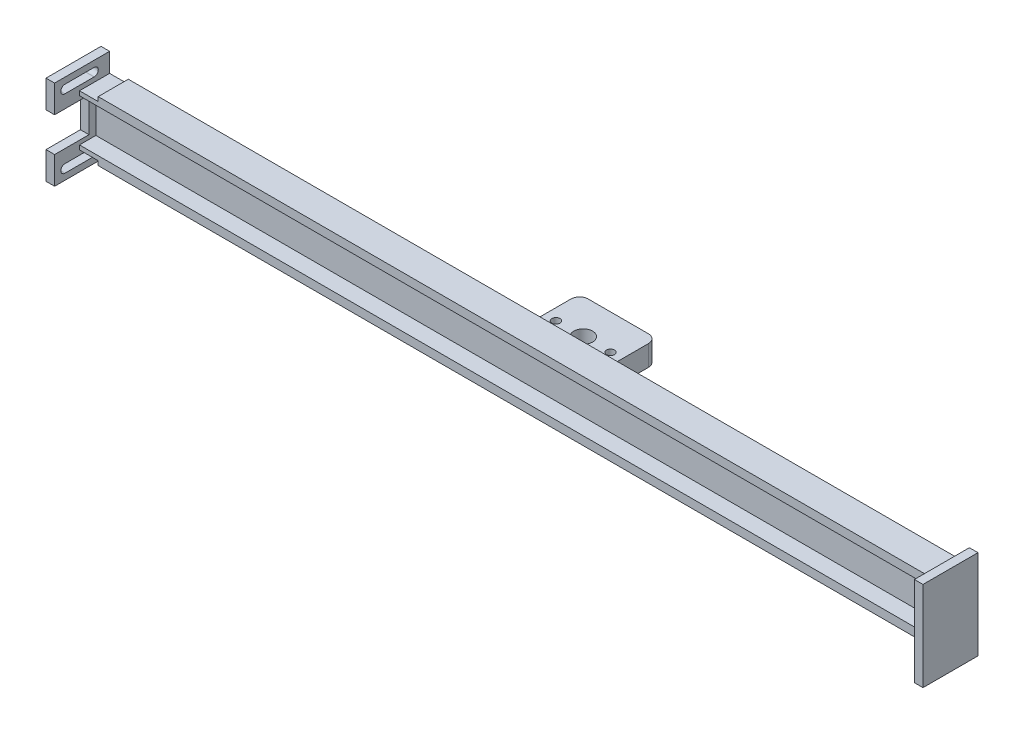
from build123d import *

# Parameters (mm, degrees)
BOSS_EXTRUDE1_DEPTH = 250
SKETCH16_W          = 22.5
SKETCH16_H          = 25.4
SKETCH16_R          = 1.175
SKETCH16_R_2        = 2.75
BOSS_EXTRUDE4_DEPTH = 6
SKETCH17_W          = 22.5
SKETCH17_H          = 6
CUT_EXTRUDE10_DEPTH = 2.5
SKETCH20_W          = 26
SKETCH20_H          = 16
BOSS_EXTRUDE7_DEPTH = 2.5
CUT_EXTRUDE12_DEPTH = 2.5
SKETCH22_W          = 10
SKETCH22_H          = 10
CUT_EXTRUDE13_DEPTH = 10
SKETCH23_W          = 5.437321705
SKETCH23_H          = 8.7625
CUT_EXTRUDE14_DEPTH = 1.25
SKETCH24_W          = 26
SKETCH24_H          = 16
BOSS_EXTRUDE8_DEPTH = 2.5
FILLET1_R           = 2.5


with BuildPart() as part:
    # Sketch1 → Boss-Extrude1 (new body)
    with BuildSketch(Plane.YZ):
        Polygon((0, 4.7625), (-2.5, 4.7625), (-2.5, -4), (14.8825, -4), (14.8825, 4.7625), (12.3825, 4.7625), (12.3825, 0), (0, 0), align=None)
    extrude(amount=BOSS_EXTRUDE1_DEPTH)

    # Sketch16 → Boss-Extrude4 (add)
    with BuildSketch(Plane.XZ.offset(2.5)):
        with Locations((125, -16.7)):
            Rectangle(SKETCH16_W, SKETCH16_H)
        with Locations((117.0625, -16.7)):
            Circle(SKETCH16_R, mode=Mode.SUBTRACT)
        with Locations((132.9375, -16.7)):
            Circle(SKETCH16_R, mode=Mode.SUBTRACT)
        with Locations((125, -16.7)):
            Circle(SKETCH16_R_2, mode=Mode.SUBTRACT)
    extrude(amount=-BOSS_EXTRUDE4_DEPTH)

    # Sketch17 → Cut-Extrude10 (cut)
    with BuildSketch(Plane(origin=(0, 0, -29.4), x_dir=(1, 0, 0), z_dir=(0, 0, -1))):
        with Locations((125, -0.5)):
            Rectangle(SKETCH17_W, SKETCH17_H)
    extrude(amount=-CUT_EXTRUDE10_DEPTH, mode=Mode.SUBTRACT)

    # Sketch20 → Boss-Extrude7 (add)
    with BuildSketch(Plane(origin=(0, 0, 0), x_dir=(0, -1, 0), z_dir=(-1, 0, 0))):
        with Locations((-6.19125, 4)):
            Rectangle(SKETCH20_W, SKETCH20_H)
    extrude(amount=BOSS_EXTRUDE7_DEPTH)

    # Sketch21 → Cut-Extrude12 (cut)
    with BuildSketch(Plane(origin=(-2.5, 0, 0), x_dir=(0, -1, 0), z_dir=(-1, 0, 0))):
        with BuildLine():
            Line((-14.99125, 9), (-14.99125, 0.5))
            ThreePointArc((-14.99125, 0.5), (-16.19125, -0.7), (-17.39125, 0.5))
            Line((-17.39125, 0.5), (-17.39125, 9))
            ThreePointArc((-17.39125, 9), (-16.19125, 10.2), (-14.99125, 9))
        make_face()
        with BuildLine():
            Line((2.60875, 9), (2.60875, 0.5))
            ThreePointArc((2.60875, 0.5), (3.80875, -0.7), (5.00875, 0.5))
            Line((5.00875, 0.5), (5.00875, 9))
            ThreePointArc((5.00875, 9), (3.80875, 10.2), (2.60875, 9))
        make_face()
    extrude(amount=-CUT_EXTRUDE12_DEPTH, mode=Mode.SUBTRACT)

    # Sketch22 → Cut-Extrude13 (cut)
    with BuildSketch(Plane(origin=(-2.5, 0, 0), x_dir=(0, -1, 0), z_dir=(-1, 0, 0))):
        with Locations((-6.19125, 7)):
            Rectangle(SKETCH22_W, SKETCH22_H)
    extrude(amount=-CUT_EXTRUDE13_DEPTH, mode=Mode.SUBTRACT)

    # Sketch23 → Cut-Extrude14 (cut)
    with BuildSketch(Plane(origin=(0, 14.8825, 0), x_dir=(-1, 0, 0), z_dir=(0, 1, 0))):
        with Locations((-2.718660853, 0.38125)):
            Rectangle(SKETCH23_W, SKETCH23_H)
    cut_extrude14 = extrude(amount=-CUT_EXTRUDE14_DEPTH, mode=Mode.SUBTRACT)

    # Mirror8: Cut-Extrude14 across plane
    add(cut_extrude14.mirror(Plane.ZX.offset(6.19125)), mode=Mode.SUBTRACT)

    # Sketch24 → Boss-Extrude8 (add)
    with BuildSketch(Plane.YZ.offset(250)):
        with Locations((6.19125, 4)):
            Rectangle(SKETCH24_W, SKETCH24_H)
    extrude(amount=BOSS_EXTRUDE8_DEPTH)

    # Fillet1
    fillet1_edges = [part.edges().sort_by_distance(p)[0] for p in [
        (136.25, 0.5, -26.9),
        (113.75, 0.5, -26.9),
    ]]
    fillet(fillet1_edges, radius=FILLET1_R)


solid = part.part
